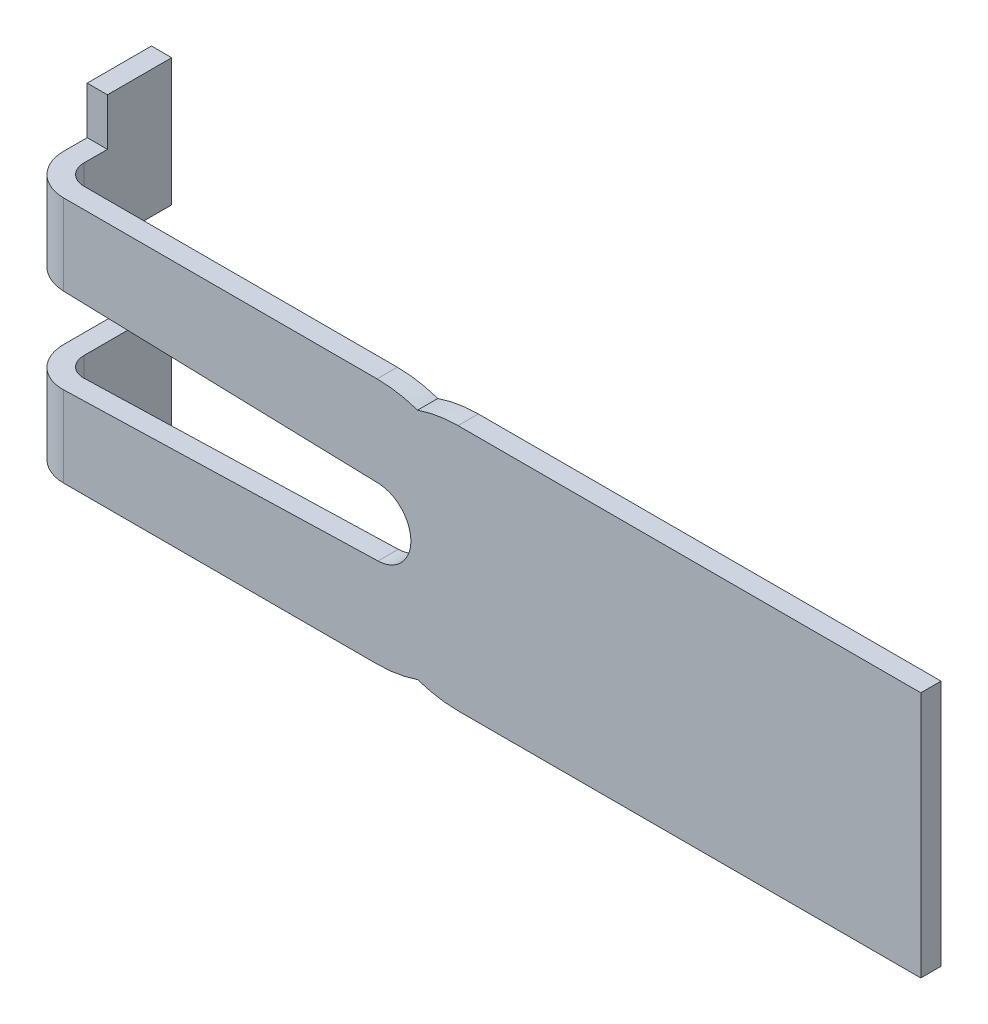
from build123d import *

# Parameters (mm, degrees)
BASE_EXTRU_MINCE_DEPTH  = 1.83
ENL_V_MAT_EXTRU_1_DEPTH = 2.9
ESQUISSE3_W             = 0.3
ESQUISSE3_H             = 0.952232616
BOSS_EXTRU_1_DEPTH      = 0.7
ENL_V_MAT_EXTRU_2_DEPTH = 2.9


with BuildPart() as part:
    # Esquisse1 → Base-Extru.-Mince (new body, symmetric)
    with BuildSketch(Plane(origin=(0, 0, 0), x_dir=(1, 0, 0), z_dir=(0, 1, 0))):
        with BuildLine():
            Line((0, 0), (0, -1.3))
            ThreePointArc((0, -1.3), (0.087867966, -1.512132034), (0.3, -1.6))
            Line((0.3, -1.6), (13, -1.6))
            Line((13, -1.6), (13, -1.9))
            Line((13, -1.9), (0.3, -1.9))
            ThreePointArc((0.3, -1.9), (-0.124264069, -1.724264069), (-0.3, -1.3))
            Line((-0.3, -1.3), (-0.3, 0))
            Line((-0.3, 0), (0, 0))
        make_face()
    extrude(amount=BASE_EXTRU_MINCE_DEPTH, both=True)

    # Esquisse2 → Enlèv. mat.-Extru.1 (cut, through all)
    with BuildSketch(Plane.XY):
        with BuildLine():
            Line((-0.3, 0.65), (4.957585181, 0.499796078))
            ThreePointArc((4.957585181, 0.499796078), (5.443306509, 0), (4.957585181, -0.499796078))
            Line((4.957585181, -0.499796078), (-0.3, -0.65))
            Line((-0.3, -0.65), (-0.3, 0.65))
        make_face()
    extrude(amount=ENL_V_MAT_EXTRU_1_DEPTH, mode=Mode.SUBTRACT)

    # Esquisse3 → Boss.-Extru.1 (add)
    with BuildSketch(Plane(origin=(0, 1.83, 0), x_dir=(-1, 0, 0), z_dir=(0, 1, 0))):
        with Locations((0.15, 0.476116308)):
            Rectangle(ESQUISSE3_W, ESQUISSE3_H)
    boss_extru_1 = extrude(amount=BOSS_EXTRU_1_DEPTH)

    # Symétrie1: Boss.-Extru.1 across plane
    add(boss_extru_1.mirror(Plane.ZX))

    # Esquisse4 → Enlèv. mat.-Extru.2 (cut, through all)
    with BuildSketch(Plane.XY):
        with BuildLine():
            Line((4.943306509, -1.83), (6.143306509, -1.83))
            ThreePointArc((6.143306509, -1.83), (5.839072788, -1.804533691), (5.543306509, -1.728843544))
            ThreePointArc((5.543306509, -1.728843544), (5.247540231, -1.804533691), (4.943306509, -1.83))
        make_face()
        with BuildLine():
            Line((4.943306509, 1.83), (6.143306509, 1.83))
            ThreePointArc((6.143306509, 1.83), (5.839072788, 1.804533691), (5.543306509, 1.728843544))
            ThreePointArc((5.543306509, 1.728843544), (5.247540231, 1.804533691), (4.943306509, 1.83))
        make_face()
    extrude(amount=ENL_V_MAT_EXTRU_2_DEPTH, mode=Mode.SUBTRACT)


solid = part.part
